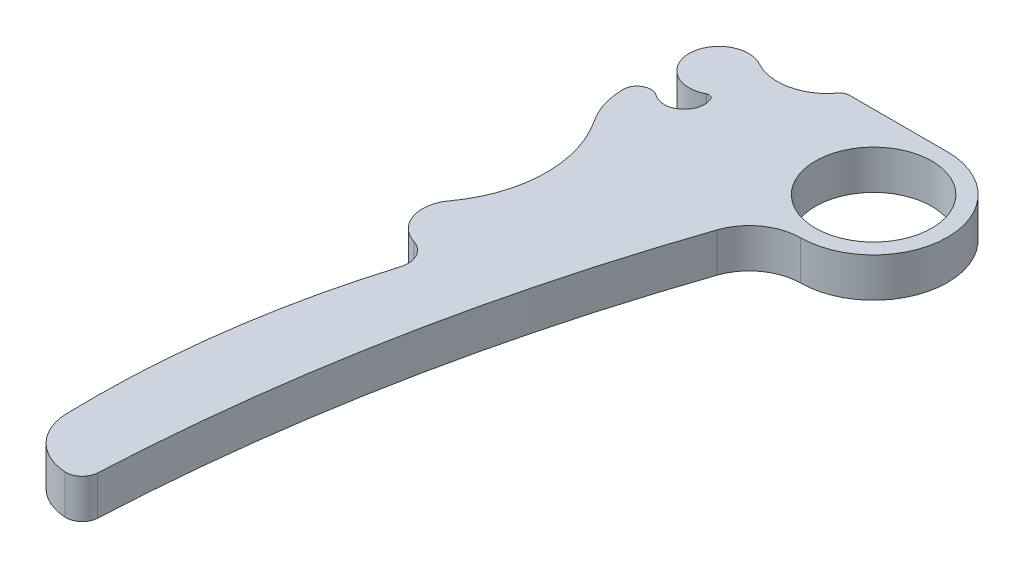
from build123d import *

# Parameters (mm, degrees)
CROQUIS1_R              = 4.446768191
SALIENTE_EXTRUIR1_DEPTH = 3


with BuildPart() as part:
    # Croquis1 → Saliente-Extruir1 (new body)
    with BuildSketch(Plane(origin=(0, 0, 0), x_dir=(1, 0, 0), z_dir=(0, 1, 0))):
        with BuildLine():
            ThreePointArc((0.04624071, -5.650316034), (5.650457939, 0.023120548), (0, 5.650505241))
            Line((0, 5.650505241), (-6.558714934, 5.650505241))
            Line((-6.558714934, 5.650505241), (-7.488201893, 5.650505241))
            ThreePointArc((-7.488201893, 5.650505241), (-7.823446184, 5.570700791), (-8.086776283, 5.348406518))
            ThreePointArc((-8.086776283, 5.348406518), (-10.345385807, 3.886616052), (-13.007001279, 4.2789825))
            ThreePointArc((-13.007001279, 4.2789825), (-16.387283849, 2.318589671), (-13.058926803, 0.271276879))
            ThreePointArc((-13.058926803, 0.271276879), (-12.757166646, 0.290746917), (-12.539738197, 0.080596626))
            ThreePointArc((-12.539738197, 0.080596626), (-13.014703567, -1.709451511), (-14.866296536, -1.747764912))
            ThreePointArc((-14.866296536, -1.747764912), (-15.955750761, -1.665010286), (-16.52578224, -2.597117012))
            ThreePointArc((-16.52578224, -2.597117012), (-16.279366787, -4.255127031), (-15.561421483, -5.769812589))
            ThreePointArc((-15.561421483, -5.769812589), (-13.964054479, -11.235683534), (-15.795045548, -16.627788712))
            ThreePointArc((-15.795045548, -16.627788712), (-16.170307553, -18.987627294), (-14.467414276, -20.663877332))
            ThreePointArc((-14.467414276, -20.663877332), (-13.433418752, -21.52247795), (-13.304756207, -22.860307429))
            ThreePointArc((-13.304756207, -22.860307429), (-15.728318678, -33.985404535), (-16.335024288, -45.355248377))
            ThreePointArc((-16.335024288, -45.355248377), (-15.195125313, -48.044049913), (-12.531403036, -49.241383204))
            ThreePointArc((-12.531403036, -49.241383204), (-11.635581739, -48.920558505), (-11.228904984, -48.060303717))
            ThreePointArc((-11.228904984, -48.060303717), (-8.826265832, -27.920860577), (-3.642833223, -8.31214131))
            ThreePointArc((-3.642833223, -8.31214131), (-2.222317675, -6.393569379), (0.04624071, -5.650316034))
        make_face()
        Circle(CROQUIS1_R, mode=Mode.SUBTRACT)
    extrude(amount=SALIENTE_EXTRUIR1_DEPTH)


solid = part.part
